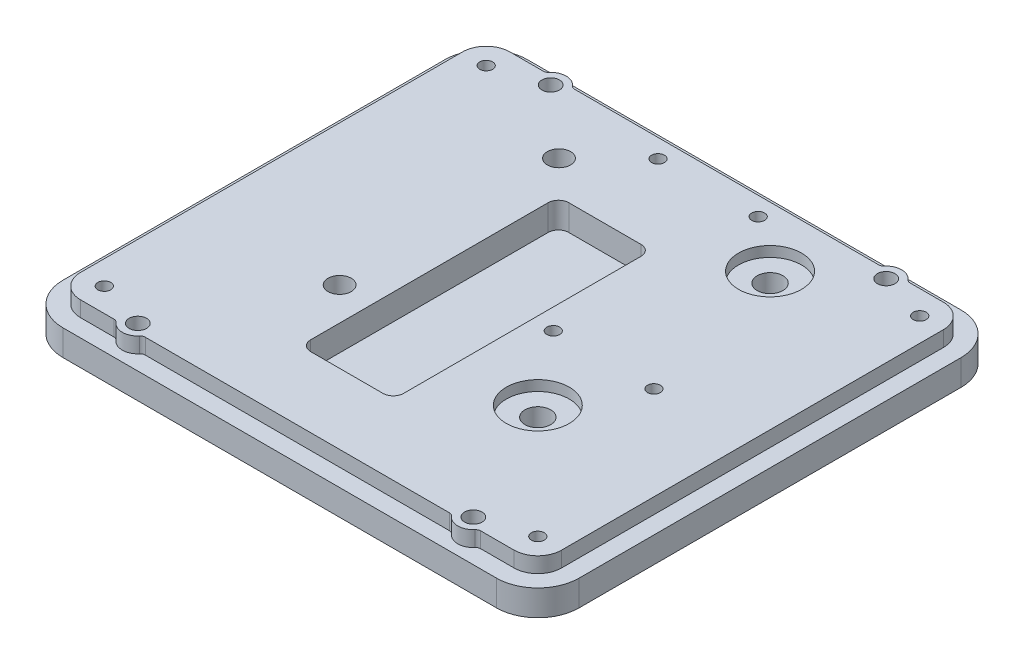
from build123d import *

# Parameters (mm, degrees)
SKETCH1_W                      = 100
SKETCH1_H                      = 90
BOSS_EXTRUDE1_DEPTH            = 8
FILLET1_R                      = 8
SKETCH6_R                      = 6.1
CUT_EXTRUDE1_DEPTH             = 2
SKETCH7_OUTSIDE_W              = 128.954
SKETCH7_OUTSIDE_H              = 118.954
CUT_EXTRUDE2_DEPTH             = 3
M3X0_5_TAPPED_HOLE1_D          = 2.5
M6X1_0_TAPPED_HOLE2_D          = 5
SKETCH12_R                     = 3
SKETCH12_R_2                   = 1.660846167
BOSS_EXTRUDE2_DEPTH            = 3
CBORE_FOR_M3_SHCS1_D           = 3.4
CBORE_FOR_M3_SHCS1_CBORE_D     = 6.5
CBORE_FOR_M3_SHCS1_CBORE_DEPTH = 3
FILLET2_R                      = 1
SKETCH15_W                     = 18
SKETCH15_H                     = 50
CUT_EXTRUDE3_DEPTH             = 5
FILLET3_R                      = 2
CBORE_FOR_M4_SHCS1_D           = 4.5
CBORE_FOR_M4_SHCS1_CBORE_D     = 8
CBORE_FOR_M4_SHCS1_CBORE_DEPTH = 4


with BuildPart() as part:
    # Sketch1 → Boss-Extrude1 (new body)
    with BuildSketch(Plane(origin=(0, 0, 0), x_dir=(1, 0, 0), z_dir=(0, 1, 0))):
        Rectangle(SKETCH1_W, SKETCH1_H)
    extrude(amount=BOSS_EXTRUDE1_DEPTH)

    # Fillet1
    fillet1_edges = [part.edges().sort_by_distance(p)[0] for p in [
        (50, 4, 45),
        (-50, 4, 45),
        (-50, 4, -45),
        (50, 4, -45),
    ]]
    fillet(fillet1_edges, radius=FILLET1_R)

    # Sketch6 → Cut-Extrude1 (cut)
    with BuildSketch(Plane(origin=(0, 8, 0), x_dir=(1, 0, 0), z_dir=(0, 1, 0))):
        with Locations((20, 30)):
            Circle(SKETCH6_R)
        with Locations((20, -15)):
            Circle(SKETCH6_R)
    extrude(amount=-CUT_EXTRUDE1_DEPTH, mode=Mode.SUBTRACT)

    # Sketch7 outside → Cut-Extrude2 (cut)
    with BuildSketch(Plane(origin=(0, 8, 0), x_dir=(1, 0, 0), z_dir=(0, 1, 0))):
        Rectangle(SKETCH7_OUTSIDE_W, SKETCH7_OUTSIDE_H)
        with BuildLine():
            Line((-42, -41.6), (42, -41.6))
            ThreePointArc((42, -41.6), (45.252691193, -40.252691193), (46.6, -37))
            Line((46.6, -37), (46.6, 37))
            ThreePointArc((46.6, 37), (45.252691193, 40.252691193), (42, 41.6))
            Line((42, 41.6), (-42, 41.6))
            ThreePointArc((-42, 41.6), (-45.252691193, 40.252691193), (-46.6, 37))
            Line((-46.6, 37), (-46.6, -37))
            ThreePointArc((-46.6, -37), (-45.252691193, -40.252691193), (-42, -41.6))
        make_face(mode=Mode.SUBTRACT)
    extrude(amount=-CUT_EXTRUDE2_DEPTH, mode=Mode.SUBTRACT)

    # M3x0.5 Tapped Hole1 (through all)
    with Locations(Plane(origin=(0, 8, 0), x_dir=(1, 0, 0), z_dir=(0, 1, 0))):
        with Locations((-42, -37), (-42, 37), (42, 37), (42, -37), (-9.7, 38), (9.7, 38), (28.5, -1), (9, -1)):
            Hole(M3X0_5_TAPPED_HOLE1_D / 2)

    # M6x1.0 Tapped Hole2 (through all)
    with Locations(Plane(origin=(0, 8, 0), x_dir=(1, 0, 0), z_dir=(0, 1, 0))):
        with Locations((20, 30), (20, -15)):
            Hole(M6X1_0_TAPPED_HOLE2_D / 2)

    # Sketch12 → Boss-Extrude2 (add)
    with BuildSketch(Plane(origin=(0, 8, 0), x_dir=(1, 0, 0), z_dir=(0, 1, 0))):
        with Locations((-32.5, 40)):
            Circle(SKETCH12_R)
        with Locations((-32.5, 40)):
            Circle(SKETCH12_R_2, mode=Mode.SUBTRACT)
        with Locations((32.5, 40)):
            Circle(SKETCH12_R)
        with Locations((32.5, 40)):
            Circle(SKETCH12_R_2, mode=Mode.SUBTRACT)
        with Locations((-32.5, -40)):
            Circle(SKETCH12_R)
        with Locations((-32.5, -40)):
            Circle(SKETCH12_R_2, mode=Mode.SUBTRACT)
        with Locations((32.5, -40)):
            Circle(SKETCH12_R)
        with Locations((32.5, -40)):
            Circle(SKETCH12_R_2, mode=Mode.SUBTRACT)
    extrude(amount=-BOSS_EXTRUDE2_DEPTH)

    # CBORE for M3 SHCS1 (through all)
    with Locations(Plane(origin=(0, 0, 0), x_dir=(-1, 0, 0), z_dir=(0, -1, 0))):
        with Locations((32.5, -40), (-32.5, -40), (32.5, 40), (-32.5, 40)):
            CounterBoreHole(CBORE_FOR_M3_SHCS1_D / 2, CBORE_FOR_M3_SHCS1_CBORE_D / 2, CBORE_FOR_M3_SHCS1_CBORE_DEPTH)

    # Fillet2
    fillet2_edges = [part.edges().sort_by_distance(p)[0] for p in [
        (-29.962284492, 6.5, -41.6),
        (-35.037715508, 6.5, -41.6),
        (35.037715508, 6.5, -41.6),
        (29.962284492, 6.5, -41.6),
        (-35.037715508, 6.5, 41.6),
        (-29.962284492, 6.5, 41.6),
        (35.037715508, 6.5, 41.6),
        (29.962284492, 6.5, 41.6),
    ]]
    fillet(fillet2_edges, radius=FILLET2_R)

    # Sketch15 → Cut-Extrude3 (cut)
    with BuildSketch(Plane(origin=(0, 8, 0), x_dir=(1, 0, 0), z_dir=(0, 1, 0))):
        with Locations((-4, -3)):
            Rectangle(SKETCH15_W, SKETCH15_H)
    extrude(amount=-CUT_EXTRUDE3_DEPTH, mode=Mode.SUBTRACT)

    # Fillet3
    fillet3_edges = [part.edges().sort_by_distance(p)[0] for p in [
        (-13, 5.5, 28),
        (-13, 5.5, -22),
        (5, 5.5, -22),
        (5, 5.5, 28),
    ]]
    fillet(fillet3_edges, radius=FILLET3_R)

    # CBORE for M4 SHCS1 (through all)
    with Locations(Plane(origin=(0, 0, 0), x_dir=(-1, 0, 0), z_dir=(0, -1, 0))):
        with Locations((19.4, -14), (19.4, 28.5)):
            CounterBoreHole(CBORE_FOR_M4_SHCS1_D / 2, CBORE_FOR_M4_SHCS1_CBORE_D / 2, CBORE_FOR_M4_SHCS1_CBORE_DEPTH)


solid = part.part
